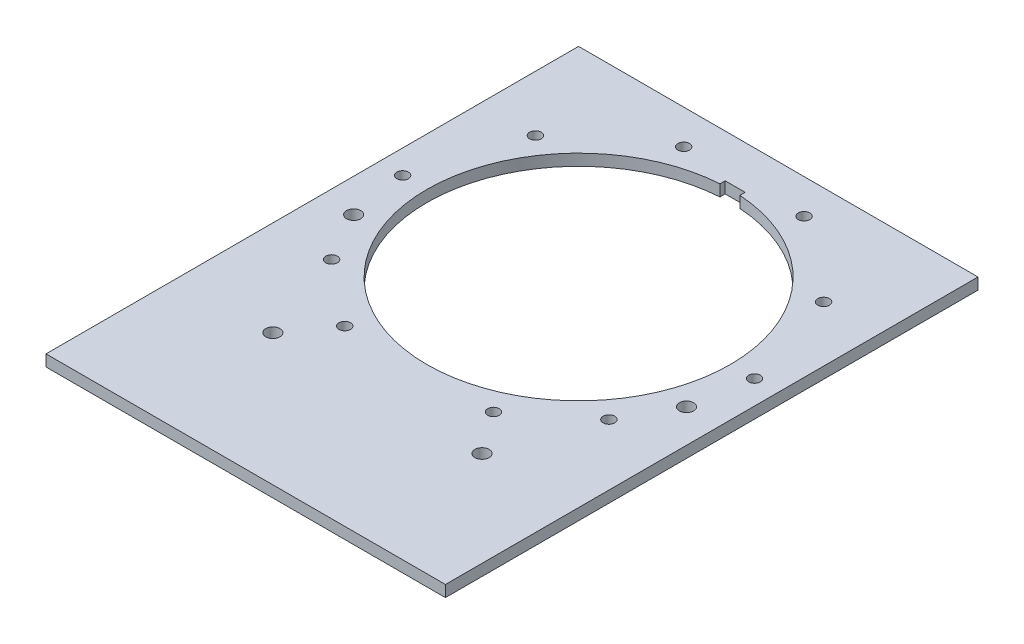
from build123d import *

# Parameters (mm, degrees)
ESQUISSE1_W        = 420
ESQUISSE1_H        = 560
ESQUISSE1_R        = 6.1
ESQUISSE1_R_2      = 7.5
BOSS_EXTRU_1_DEPTH = 12


with BuildPart() as part:
    # Esquisse1 → Boss.-Extru.1 (new body)
    with BuildSketch(Plane(origin=(0, 0, 0), x_dir=(1, 0, 0), z_dir=(0, 1, 0))):
        with Locations((0, -70)):
            Rectangle(ESQUISSE1_W, ESQUISSE1_H)
        with Locations(Location((-63.273726515, 173.843134845, 0), (0, 0, 270))):  # turned: the seam where the file's is
            Circle(ESQUISSE1_R, mode=Mode.SUBTRACT)
        with Locations(Location((-175, -61.5, 0), (0, 0, 270))):  # turned: the seam where the file's is
            Circle(ESQUISSE1_R_2, mode=Mode.SUBTRACT)
        with Locations(Location((110.0032143, -211.5, 0), (0, 0, 270))):  # turned: the seam where the file's is
            Circle(ESQUISSE1_R_2, mode=Mode.SUBTRACT)
        with Locations(Location((175, -61.5, 0), (0, 0, 270))):  # turned: the seam where the file's is
            Circle(ESQUISSE1_R_2, mode=Mode.SUBTRACT)
        with Locations(Location((185, 0, 0), (0, 0, 270))):  # turned: the seam where the file's is
            Circle(ESQUISSE1_R, mode=Mode.SUBTRACT)
        with Locations(Location((-109.9967857, -211.5, 0), (0, 0, 270))):  # turned: the seam where the file's is
            Circle(ESQUISSE1_R_2, mode=Mode.SUBTRACT)
        with Locations(Location((151.543128193, 106.111640725, 0), (0, 0, 90))):  # turned: the seam where the file's is
            Circle(ESQUISSE1_R, mode=Mode.SUBTRACT)
        with Locations(Location((-151.543128193, 106.111640725, 0), (0, 0, 270))):  # turned: the seam where the file's is
            Circle(ESQUISSE1_R, mode=Mode.SUBTRACT)
        with Locations(Location((-185, 0, 0), (0, 0, 90))):  # turned: the seam where the file's is
            Circle(ESQUISSE1_R, mode=Mode.SUBTRACT)
        with Locations(Location((63.273726515, 173.843134845, 0), (0, 0, 90))):  # turned: the seam where the file's is
            Circle(ESQUISSE1_R, mode=Mode.SUBTRACT)
        with Locations(Location((-145.781989417, -113.897372935, 0), (0, 0, 270))):  # turned: the seam where the file's is
            Circle(ESQUISSE1_R, mode=Mode.SUBTRACT)
        with Locations(Location((-78.184378422, -167.666940602, 0), (0, 0, 270))):  # turned: the seam where the file's is
            Circle(ESQUISSE1_R, mode=Mode.SUBTRACT)
        with Locations(Location((145.781989417, -113.897372935, 0), (0, 0, 90))):  # turned: the seam where the file's is
            Circle(ESQUISSE1_R, mode=Mode.SUBTRACT)
        with Locations(Location((78.184378422, -167.666940602, 0), (0, 0, 90))):  # turned: the seam where the file's is
            Circle(ESQUISSE1_R, mode=Mode.SUBTRACT)
        with BuildLine():
            Line((10.5, 164.654013459), (10.5, 159.154013459))
            ThreePointArc((10.5, 159.154013459), (0, -159.5), (-10.5, 159.154013459))
            Line((-10.5, 159.154013459), (-10.5, 164.654013459))
            Line((-10.5, 164.654013459), (10.5, 164.654013459))
        make_face(mode=Mode.SUBTRACT)
    extrude(amount=BOSS_EXTRU_1_DEPTH)


solid = part.part
